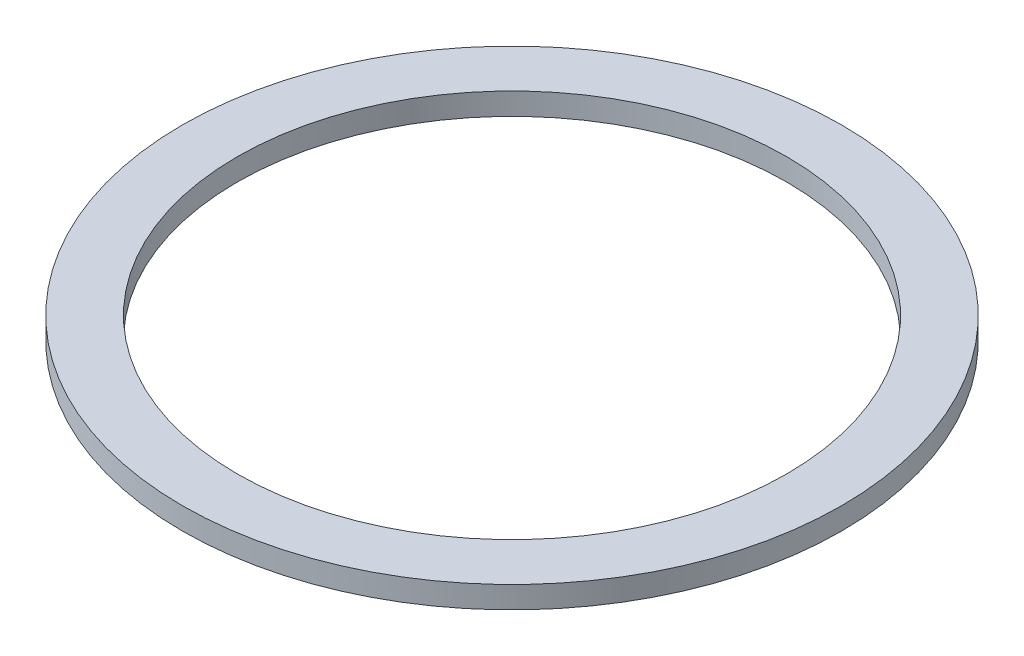
from build123d import *


with BuildPart() as part:
    # Эскиз2 → Повернуть1 (revolve)
    with BuildSketch(Plane.XY):
        with BuildLine():
            Line((25, 2), (25, 0))
            Line((25, 0), (26.085786438, 0))
            ThreePointArc((26.085786438, 0), (27.5, 1), (28.914213562, 0))
            Line((28.914213562, 0), (30, 0))
            Line((30, 0), (30, 2))
            Line((30, 2), (25, 2))
        make_face()
    revolve(axis=Axis((0, 22.758002115, 0), (0, -1, 0)))


solid = part.part
